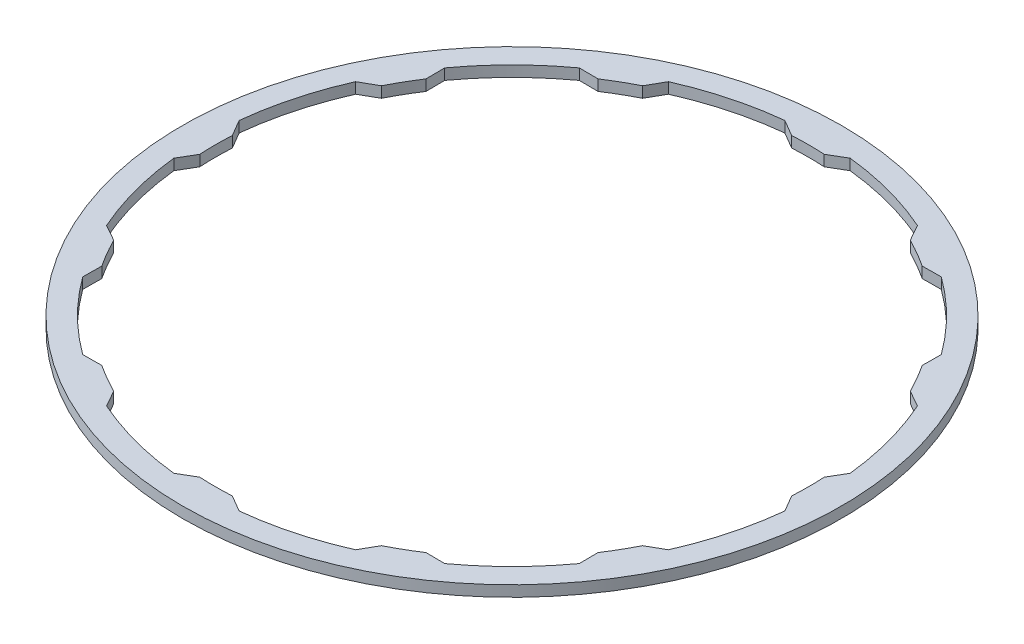
from build123d import *

# Parameters (mm, degrees)
SKETCH1_R           = 15.3924
BOSS_EXTRUDE1_DEPTH = 0.508


with BuildPart() as part:
    # Sketch1 → Boss-Extrude1 (new body)
    with BuildSketch(Plane(origin=(0, 0, 0), x_dir=(1, 0, 0), z_dir=(0, 1, 0))):
        Circle(SKETCH1_R)
        with BuildLine():
            Line((-1.524, 14.269850209), (-0.762, 13.822011612))
            ThreePointArc((-0.762, 13.822011612), (0, 13.843), (0.762, 13.822011612))
            Line((0.762, 13.822011612), (1.524, 14.269850209))
            ThreePointArc((1.524, 14.269850209), (3.714312116, 13.862001533), (5.815102389, 13.12005279))
            Line((5.815102389, 13.12005279), (6.251094448, 12.351213187))
            ThreePointArc((6.251094448, 12.351213187), (6.9215, 11.988389665), (7.570917164, 11.589213187))
            Line((7.570917164, 11.589213187), (8.45474782, 11.59605279))
            ThreePointArc((8.45474782, 11.59605279), (10.147689417, 10.147689417), (11.59605279, 8.45474782))
            Line((11.59605279, 8.45474782), (11.589213187, 7.570917164))
            ThreePointArc((11.589213187, 7.570917164), (11.988389665, 6.9215), (12.351213187, 6.251094448))
            Line((12.351213187, 6.251094448), (13.12005279, 5.815102389))
            ThreePointArc((13.12005279, 5.815102389), (13.862001533, 3.714312116), (14.269850209, 1.524))
            Line((14.269850209, 1.524), (13.822011612, 0.762))
            ThreePointArc((13.822011612, 0.762), (13.843, 0), (13.822011612, -0.762))
            Line((13.822011612, -0.762), (14.269850209, -1.524))
            ThreePointArc((14.269850209, -1.524), (13.862001533, -3.714312116), (13.12005279, -5.815102389))
            Line((13.12005279, -5.815102389), (12.351213187, -6.251094448))
            ThreePointArc((12.351213187, -6.251094448), (11.988389665, -6.9215), (11.589213187, -7.570917164))
            Line((11.589213187, -7.570917164), (11.59605279, -8.45474782))
            ThreePointArc((11.59605279, -8.45474782), (10.147689417, -10.147689417), (8.45474782, -11.59605279))
            Line((8.45474782, -11.59605279), (7.570917164, -11.589213187))
            ThreePointArc((7.570917164, -11.589213187), (6.9215, -11.988389665), (6.251094448, -12.351213187))
            Line((6.251094448, -12.351213187), (5.815102389, -13.12005279))
            ThreePointArc((5.815102389, -13.12005279), (3.714312116, -13.862001533), (1.524, -14.269850209))
            Line((1.524, -14.269850209), (0.762, -13.822011612))
            ThreePointArc((0.762, -13.822011612), (0, -13.843), (-0.762, -13.822011612))
            Line((-0.762, -13.822011612), (-1.524, -14.269850209))
            ThreePointArc((-1.524, -14.269850209), (-3.714312116, -13.862001533), (-5.815102389, -13.12005279))
            Line((-5.815102389, -13.12005279), (-6.251094448, -12.351213187))
            ThreePointArc((-6.251094448, -12.351213187), (-6.9215, -11.988389665), (-7.570917164, -11.589213187))
            Line((-7.570917164, -11.589213187), (-8.45474782, -11.59605279))
            ThreePointArc((-8.45474782, -11.59605279), (-10.147689417, -10.147689417), (-11.59605279, -8.45474782))
            Line((-11.59605279, -8.45474782), (-11.589213187, -7.570917164))
            ThreePointArc((-11.589213187, -7.570917164), (-11.988389665, -6.9215), (-12.351213187, -6.251094448))
            Line((-12.351213187, -6.251094448), (-13.12005279, -5.815102389))
            ThreePointArc((-13.12005279, -5.815102389), (-13.862001533, -3.714312116), (-14.269850209, -1.524))
            Line((-14.269850209, -1.524), (-13.822011612, -0.762))
            ThreePointArc((-13.822011612, -0.762), (-13.843, 0), (-13.822011612, 0.762))
            Line((-13.822011612, 0.762), (-14.269850209, 1.524))
            ThreePointArc((-14.269850209, 1.524), (-13.862001533, 3.714312116), (-13.12005279, 5.815102389))
            Line((-13.12005279, 5.815102389), (-12.351213187, 6.251094448))
            ThreePointArc((-12.351213187, 6.251094448), (-11.988389665, 6.9215), (-11.589213187, 7.570917164))
            Line((-11.589213187, 7.570917164), (-11.59605279, 8.45474782))
            ThreePointArc((-11.59605279, 8.45474782), (-10.147689417, 10.147689417), (-8.45474782, 11.59605279))
            Line((-8.45474782, 11.59605279), (-7.570917164, 11.589213187))
            ThreePointArc((-7.570917164, 11.589213187), (-6.9215, 11.988389665), (-6.251094448, 12.351213187))
            Line((-6.251094448, 12.351213187), (-5.815102389, 13.12005279))
            ThreePointArc((-5.815102389, 13.12005279), (-3.714312116, 13.862001533), (-1.524, 14.269850209))
        make_face(mode=Mode.SUBTRACT)
    extrude(amount=BOSS_EXTRUDE1_DEPTH)


solid = part.part
